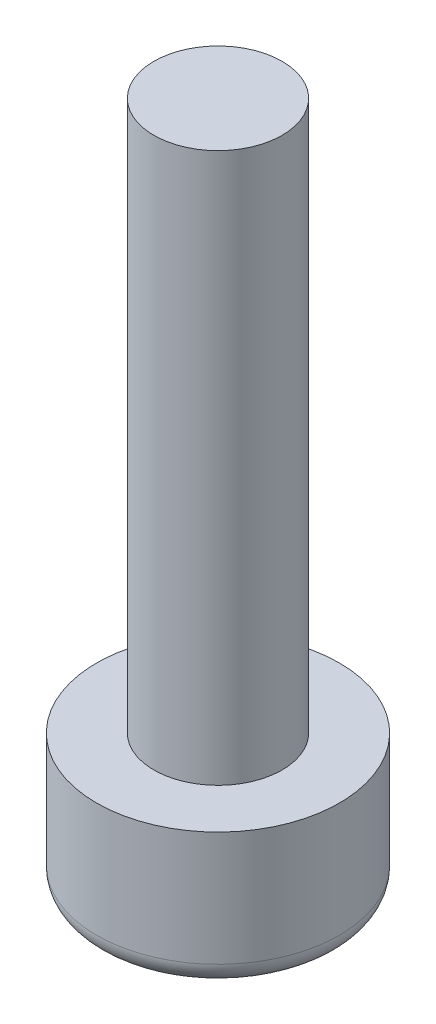
from build123d import *

# Parameters (mm, degrees)
CUT_EXTRUDE1_DEPTH = 2
FILLET1_R          = 0.5


with BuildPart() as part:
    # Sketch2 → Revolve1 (revolve)
    with BuildSketch(Plane.XY):
        Polygon((0, 0), (2.65, 0), (2.65, 3), (1.4, 3), (1.4, 15), (0, 15), align=None)
    revolve(axis=Axis((0, 0, 0), (0, 1, 0)))

    # Sketch3 → Cut-Extrude1 (cut)
    with BuildSketch(Plane.XZ):
        Polygon((-1.443375673, 0), (-0.721687836, -1.25), (0.721687836, -1.25), (1.443375673, 0), (0.721687836, 1.25), (-0.721687836, 1.25), align=None)
    extrude(amount=-CUT_EXTRUDE1_DEPTH, mode=Mode.SUBTRACT)

    # Sketch6 → Cut-Revolve1 (revolve, cut)
    with BuildSketch(Plane(origin=(0, 0, 0), x_dir=(-1, 0, 0), z_dir=(0, 0, -1))):
        with BuildLine():
            Line((0, 0), (0, 0.3))
            ThreePointArc((0, 0.3), (-0.887764045, 0.22445693), (-1.75, 0))
            Line((-1.75, 0), (0, 0))
        make_face()
    revolve(axis=Axis((0, 0, 0), (0, 1, 0)), mode=Mode.SUBTRACT)

    # Fillet1
    fillet1_edges = [part.edges().sort_by_distance(p)[0] for p in [
        (-2.65, 0, 0),
    ]]
    fillet(fillet1_edges, radius=FILLET1_R)


solid = part.part
